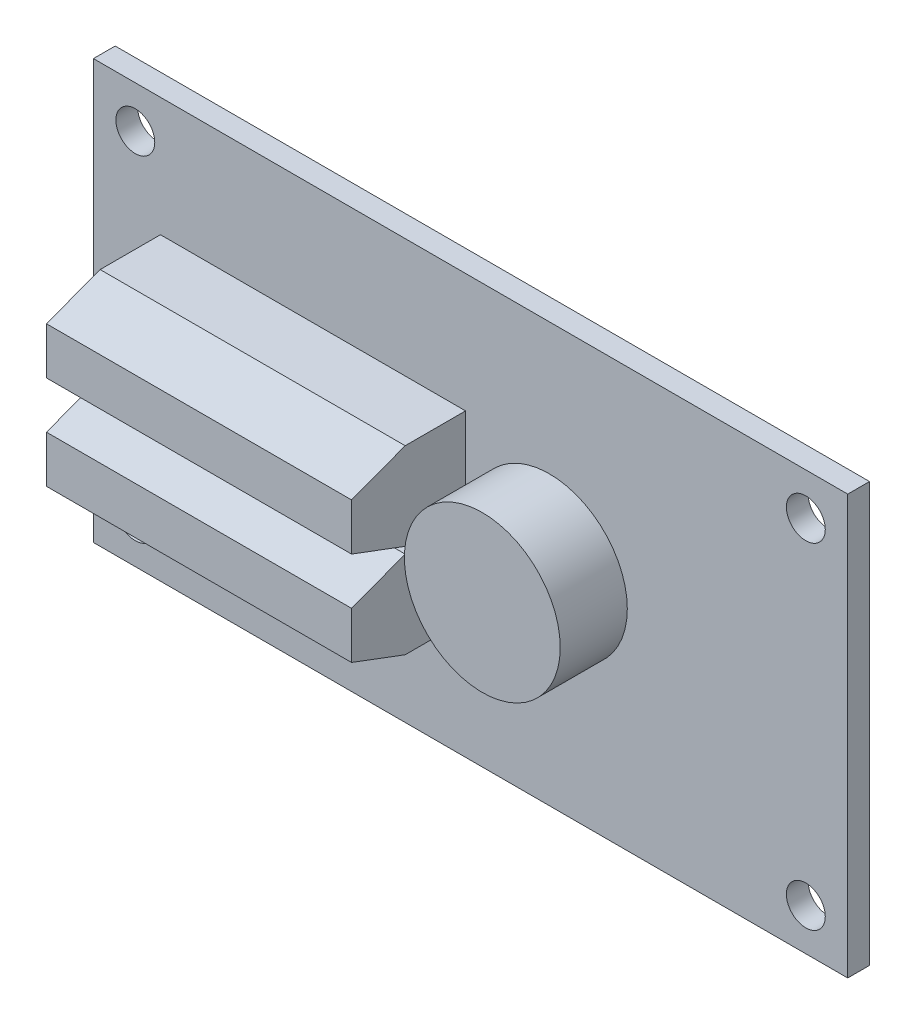
from build123d import *

# Parameters (mm, degrees)
SKETCH1_W               = 57.15
SKETCH1_H               = 31.75
BOSS_EXTRUDE1_DEPTH     = 1.651
SKETCH2_R               = 1.4732
MOUNT_HOLES_DEPTH       = 2.651
SKETCH3_W               = 23.114
SKETCH3_H               = 6.604
BOSS_EXTRUDE2_DEPTH     = 8.636
CUT_EXTRUDE1_DEPTH      = 23.114
SKETCH5_W               = 9.906
SKETCH5_H               = 9.906
LARGE_BOTTOM_CHIP_DEPTH = 1.524
SKETCH8_R               = 5.9055
BUZZER_DEPTH            = 5.08
SKETCH9_W               = 7.62
SKETCH9_H               = 5.842
USB_CONNECTOR_DEPTH     = 2.54


with BuildPart() as part:
    # Sketch1 → Boss-Extrude1 (new body)
    with BuildSketch(Plane.XY):
        Rectangle(SKETCH1_W, SKETCH1_H)
    extrude(amount=BOSS_EXTRUDE1_DEPTH)

    # Sketch2 → Mount-Holes (cut, through all)
    with BuildSketch(Plane.XY.offset(1.651)):
        with Locations((25.4, -12.7)):
            Circle(SKETCH2_R)
        with Locations((25.4, 12.7)):
            Circle(SKETCH2_R)
        with Locations((-25.4, 12.7)):
            Circle(SKETCH2_R)
        with Locations((-25.4, -12.7)):
            Circle(SKETCH2_R)
    extrude(amount=-MOUNT_HOLES_DEPTH, mode=Mode.SUBTRACT)

    # Sketch3 → Boss-Extrude2 (add)
    with BuildSketch(Plane.XY.offset(1.651)):
        with Locations((-11.938, -3.556)):
            Rectangle(SKETCH3_W, SKETCH3_H)
    boss_extrude2 = extrude(amount=BOSS_EXTRUDE2_DEPTH)

    # Sketch4 → Cut-Extrude1 (cut)
    with BuildSketch(Plane.ZY.offset(23.495)):
        Polygon((6.223, -6.858), (10.287, -5.334), (10.287, -6.858), align=None)
        Polygon((10.287, -0.254), (10.287, -1.778), (6.223, -0.254), align=None)
    cut_extrude1 = extrude(amount=-CUT_EXTRUDE1_DEPTH, mode=Mode.SUBTRACT)

    # Mirror1: Boss-Extrude2, Cut-Extrude1 across plane
    add(boss_extrude2.mirror(Plane.ZX))
    add(cut_extrude1.mirror(Plane.ZX), mode=Mode.SUBTRACT)

    # Sketch5 → Large bottom chip (add)
    with BuildSketch(Plane(origin=(0, 0, 0), x_dir=(-1, 0, 0), z_dir=(0, 0, -1))):
        with Locations((-15.24, 0)):
            Rectangle(SKETCH5_W, SKETCH5_H)
    extrude(amount=LARGE_BOTTOM_CHIP_DEPTH)

    # Sketch8 → Buzzer (add)
    with BuildSketch(Plane.XY.offset(1.651)):
        with Locations((5.969, 0)):
            Circle(SKETCH8_R)
    extrude(amount=BUZZER_DEPTH)

    # Sketch9 → USB Connector (add)
    with BuildSketch(Plane(origin=(0, 0, 0), x_dir=(-1, 0, 0), z_dir=(0, 0, -1))):
        with Locations((-0.635, -12.827)):
            Rectangle(SKETCH9_W, SKETCH9_H)
    extrude(amount=USB_CONNECTOR_DEPTH)


solid = part.part
